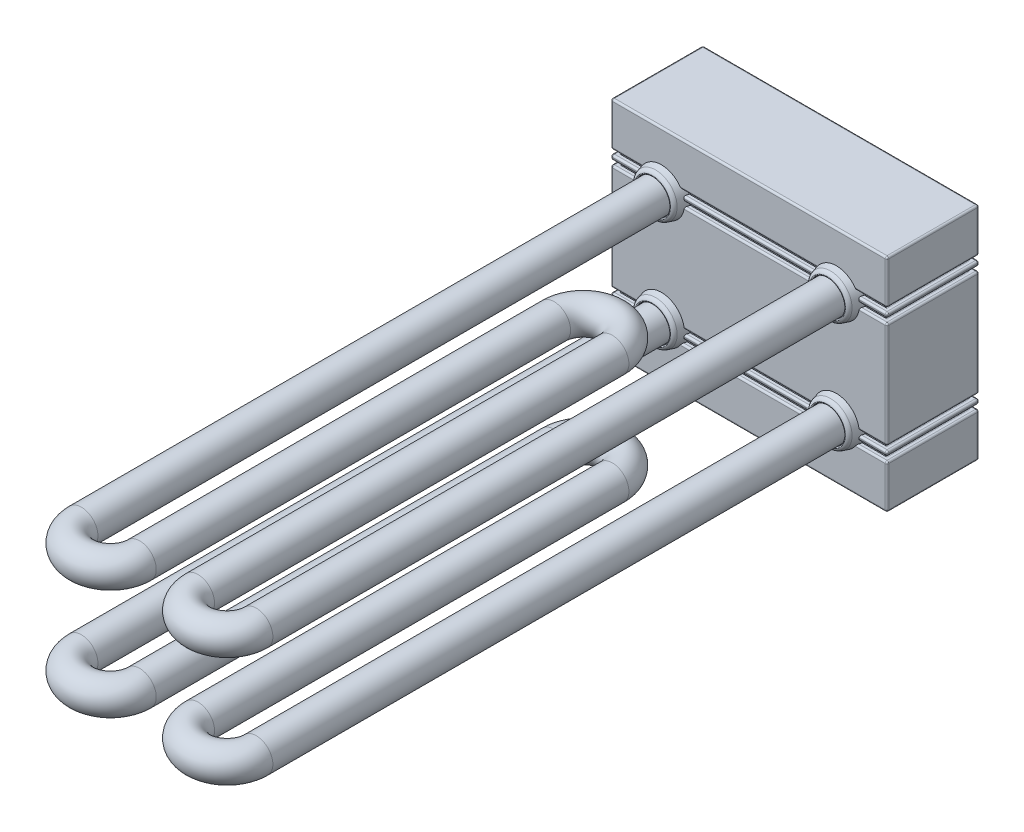
from build123d import *
from build123d.topology import SkipClean

# Parameters (mm, degrees)
SKETCH1_W                     = 38.1
SKETCH1_H                     = 30.48
BOSS_EXTRUDE1_DEPTH           = 12.7
SKETCH2_W                     = 38.1
SKETCH2_H                     = 12.7
SKETCH2_W_2                   = 36.322
SKETCH2_H_2                   = 11.43
CUT_EXTRUDE1_DEPTH            = 0.3175
LPATTERN1_COUNT               = 2
LPATTERN1_PITCH               = 1.27
MIRROR1_COPY_1_SKETCH_W       = 38.1
MIRROR1_COPY_1_SKETCH_H       = 12.7
MIRROR1_COPY_1_SKETCH_W_2     = 36.322
MIRROR1_COPY_1_SKETCH_H_2     = 11.43
MIRROR1_COPY_1_DEPTH          = 0.3175
FILLET1_R                     = 0.254
SKETCH3_R                     = 3.175
BOSS_EXTRUDE2_DEPTH           = 1.27
BOSS_EXTRUDE2_TAPER           = -15
BOSS_EXTRUDE2_OTHER_WAY_DEPTH = 1.27
BOSS_EXTRUDE2_OTHER_WAY_TAPER = 15
FILLET2_R                     = 0.635
SKETCH4_R                     = 2.347451888
CUT_EXTRUDE2_DEPTH            = 6.35
FILLET3_R                     = 0.127
SKETCH5_R                     = 2.283951888


with BuildPart() as part:
    # Sketch1 → Boss-Extrude1 (new body)
    with BuildSketch(Plane.XY):
        Rectangle(SKETCH1_W, SKETCH1_H)
    extrude(amount=BOSS_EXTRUDE1_DEPTH)

    # Sketch2 → Cut-Extrude1 (cut, symmetric)
    with BuildSketch(Plane(origin=(0, 8.89, 0), x_dir=(1, 0, 0), z_dir=(0, 1, 0))):
        with Locations((0, -6.35)):
            Rectangle(SKETCH2_W, SKETCH2_H)
        with Locations((0, -6.35)):
            Rectangle(SKETCH2_W_2, SKETCH2_H_2, mode=Mode.SUBTRACT)
    cut_extrude1 = extrude(amount=CUT_EXTRUDE1_DEPTH, both=True, mode=Mode.SUBTRACT)

    # LPattern1: Cut-Extrude1 ×2
    with Locations(*[(0, -i * LPATTERN1_PITCH, 0) for i in range(1, LPATTERN1_COUNT)]):
        add(cut_extrude1, mode=Mode.SUBTRACT)

    # Mirror1: Cut-Extrude1 across plane
    add(cut_extrude1.mirror(Plane.ZX), mode=Mode.SUBTRACT)

    # Mirror1 copy 1 sketch → Mirror1 copy 1 (cut, symmetric)
    with BuildSketch(Plane.XZ.offset(7.62)):
        with Locations((0, 6.35)):
            Rectangle(MIRROR1_COPY_1_SKETCH_W, MIRROR1_COPY_1_SKETCH_H)
        with Locations((0, 6.35)):
            Rectangle(MIRROR1_COPY_1_SKETCH_W_2, MIRROR1_COPY_1_SKETCH_H_2, mode=Mode.SUBTRACT)
    extrude(amount=MIRROR1_COPY_1_DEPTH, both=True, mode=Mode.SUBTRACT)

    # Fillet1
    fillet1_edges = [part.edges().sort_by_distance(p)[0] for p in [
        (-18.161, 8.5725, 6.35),
        (-18.161, 9.2075, 6.35),
        (18.161, 8.5725, 6.35),
        (18.161, 9.2075, 6.35),
        (-18.161, 7.3025, 6.35),
        (-18.161, 7.9375, 6.35),
        (18.161, 7.3025, 6.35),
        (18.161, 7.9375, 6.35),
        (18.161, -7.3025, 6.35),
        (18.161, -7.9375, 6.35),
        (-18.161, -7.3025, 6.35),
        (-18.161, -7.9375, 6.35),
        (18.161, -8.5725, 6.35),
        (18.161, -9.2075, 6.35),
        (-18.161, -8.5725, 6.35),
        (-18.161, -9.2075, 6.35),
        (-18.161, 8.89, 0.635),
        (0, 8.5725, 0.635),
        (18.161, 8.89, 0.635),
        (0, 9.2075, 0.635),
        (-18.161, 7.62, 0.635),
        (0, 7.3025, 0.635),
        (18.161, 7.62, 0.635),
        (0, 7.9375, 0.635),
        (18.161, -7.62, 0.635),
        (0, -7.3025, 0.635),
        (-18.161, -7.62, 0.635),
        (0, -7.9375, 0.635),
        (18.161, -8.89, 0.635),
        (0, -8.5725, 0.635),
        (-18.161, -8.89, 0.635),
        (0, -9.2075, 0.635),
        (0, 9.2075, 0),
        (0, 8.5725, 0),
        (0, 7.9375, 0),
        (-19.05, 12.22375, 0),
        (-19.05, 9.2075, 6.35),
        (-19.05, 8.255, 0),
        (-19.05, 8.5725, 6.35),
        (-19.05, 7.9375, 6.35),
        (19.05, 12.22375, 0),
        (19.05, 9.2075, 6.35),
        (-19.05, 12.22375, 12.7),
        (19.05, 12.22375, 12.7),
        (0, 9.2075, 12.7),
        (19.05, 8.5725, 6.35),
        (19.05, 8.255, 0),
        (19.05, 7.9375, 6.35),
        (-19.05, 8.255, 12.7),
        (0, 8.5725, 12.7),
        (19.05, 8.255, 12.7),
        (0, 7.9375, 12.7),
        (0, -8.5725, 12.7),
        (0, -7.9375, 12.7),
        (0, -8.5725, 0),
        (0, -7.9375, 0),
        (-19.05, -8.255, 12.7),
        (-19.05, -8.5725, 6.35),
        (-19.05, -8.255, 0),
        (-19.05, -7.9375, 6.35),
        (0, -9.2075, 0),
        (-19.05, -12.22375, 0),
        (-19.05, -9.2075, 6.35),
        (19.05, -8.255, 0),
        (19.05, -8.5725, 6.35),
        (19.05, -8.255, 12.7),
        (19.05, -7.9375, 6.35),
        (19.05, -12.22375, 0),
        (19.05, -9.2075, 6.35),
        (19.05, -12.22375, 12.7),
        (-19.05, -12.22375, 12.7),
        (0, -9.2075, 12.7),
        (19.05, 7.3025, 6.35),
        (19.05, -7.3025, 6.35),
        (19.05, 0, 0),
        (0, 7.3025, 0),
        (0, -7.3025, 0),
        (-19.05, 7.3025, 6.35),
        (-19.05, -7.3025, 6.35),
        (-19.05, 0, 0),
        (0, 7.3025, 12.7),
        (19.05, 0, 12.7),
        (0, -7.3025, 12.7),
        (-19.05, 0, 12.7),
        (19.05, 15.24, 6.35),
        (0, 15.24, 12.7),
        (-19.05, 15.24, 6.35),
        (0, 15.24, 0),
        (-19.05, -15.24, 6.35),
        (0, -15.24, 12.7),
        (19.05, -15.24, 6.35),
        (0, -15.24, 0),
    ]]
    fillet(fillet1_edges, radius=FILLET1_R)

    # Sketch3 → Boss-Extrude2 (add)
    with BuildSketch(Plane.XY.offset(12.7)):
        with Locations((-12.065, 7.62)):
            Circle(SKETCH3_R)
        with Locations((12.065, 7.62)):
            Circle(SKETCH3_R)
        with Locations((12.065, -7.62)):
            Circle(SKETCH3_R)
        with Locations((-12.065, -7.62)):
            Circle(SKETCH3_R)
    extrude(amount=-BOSS_EXTRUDE2_DEPTH, taper=BOSS_EXTRUDE2_TAPER)

    # Sketch3 → Boss-Extrude2 other way (add)
    with SkipClean():  # the faces are left unmerged after this step: merging them gives an invalid solid
        with BuildSketch(Plane.XY.offset(12.7)):
            with Locations((-12.065, 7.62)):
                Circle(SKETCH3_R)
            with Locations((12.065, 7.62)):
                Circle(SKETCH3_R)
            with Locations((12.065, -7.62)):
                Circle(SKETCH3_R)
            with Locations((-12.065, -7.62)):
                Circle(SKETCH3_R)
        extrude(amount=BOSS_EXTRUDE2_OTHER_WAY_DEPTH, taper=BOSS_EXTRUDE2_OTHER_WAY_TAPER)

    # Fillet2
    fillet2_edges = [part.edges().sort_by_distance(p)[0] for p in [
        (9.230295474, -7.62, 13.97),
        (-14.899704526, -7.62, 13.97),
        (9.230295474, 7.62, 13.97),
        (-14.899704526, 7.62, 13.97),
    ]]
    fillet(fillet2_edges, radius=FILLET2_R)

    # Sketch4 → Cut-Extrude2 (cut)
    with BuildSketch(Plane.XY.offset(13.97)):
        with Locations((-12.065, 7.62)):
            Circle(SKETCH4_R)
        with Locations((-12.065, -7.62)):
            Circle(SKETCH4_R)
        with Locations((12.065, 7.62)):
            Circle(SKETCH4_R)
        with Locations((12.065, -7.62)):
            Circle(SKETCH4_R)
    extrude(amount=-CUT_EXTRUDE2_DEPTH, mode=Mode.SUBTRACT)

    # Fillet3
    fillet3_edges = [part.edges().sort_by_distance(p)[0] for p in [
        (9.717548112, -7.62, 13.97),
        (-14.412451888, -7.62, 13.97),
        (9.717548112, 7.62, 13.97),
        (-14.412451888, 7.62, 13.97),
    ]]
    fillet(fillet3_edges, radius=FILLET3_R)

    # Sweep1: sweep along a path in Sketch6
    with BuildLine(Plane(origin=(0, 7.62, 0), x_dir=(1, 0, 0), z_dir=(0, 1, 0))) as sweep1_path:
        Line((-12.065, -7.62), (-12.065, -92.71))
        ThreePointArc((-12.065, -92.71), (-8.043333333, -96.731666667), (-4.021666667, -92.71))
        Line((-4.021666667, -92.71), (-4.021666667, -35.56))
        ThreePointArc((-4.021666667, -35.56), (0, -31.538333333), (4.021666667, -35.56))
        Line((4.021666667, -35.56), (4.021666667, -92.71))
        ThreePointArc((4.021666667, -92.71), (8.043333333, -96.731666667), (12.065, -92.71))
        Line((12.065, -92.71), (12.065, -7.62))
    # Sketch5 → Sweep1 (sweep)
    with BuildSketch(Plane.XY.offset(7.62)):
        with Locations((-12.065, 7.62)):
            Circle(SKETCH5_R)
        with Locations((-12.065, -7.62)):
            Circle(SKETCH5_R)
    sweep(path=sweep1_path.line)


solid = part.part
